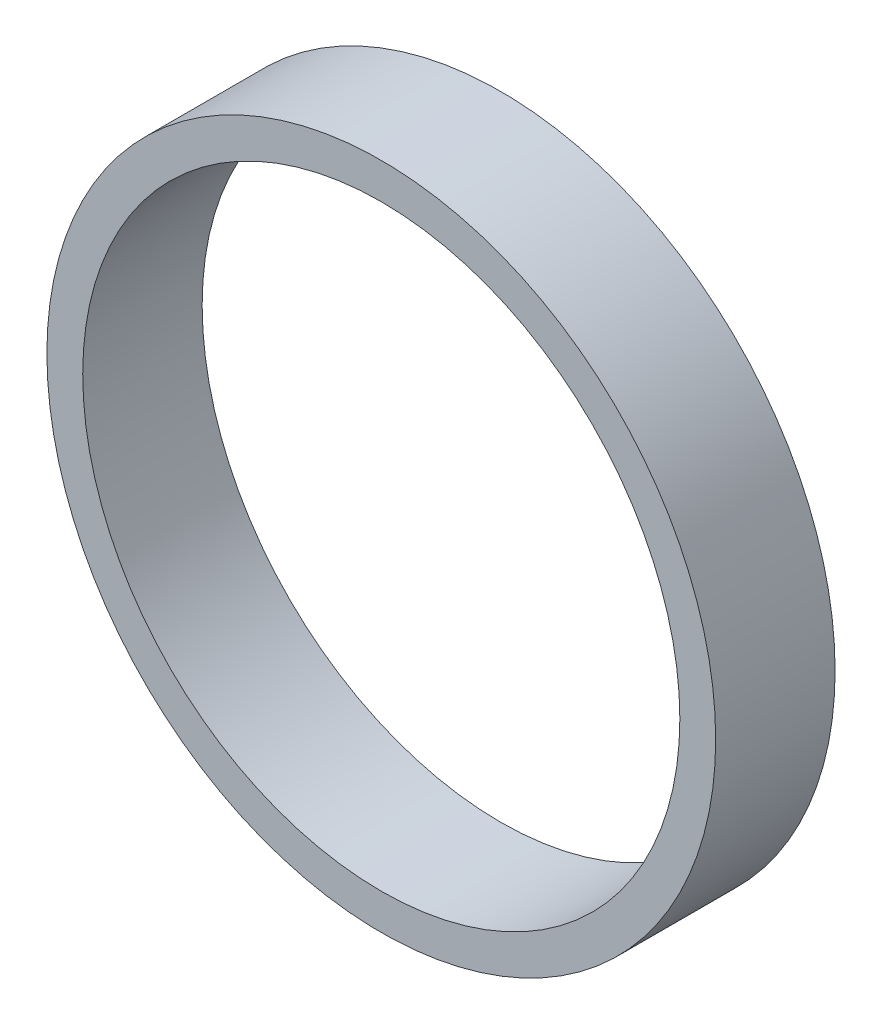
from build123d import *

# Parameters (mm, degrees)
SKETCH1_R           = 14
SKETCH1_R_2         = 12.5
BOSS_EXTRUDE1_DEPTH = 5


with BuildPart() as part:
    # Sketch1 → Boss-Extrude1 (new body)
    with BuildSketch(Plane.XY):
        Circle(SKETCH1_R)
        Circle(SKETCH1_R_2, mode=Mode.SUBTRACT)
    extrude(amount=BOSS_EXTRUDE1_DEPTH)


solid = part.part
